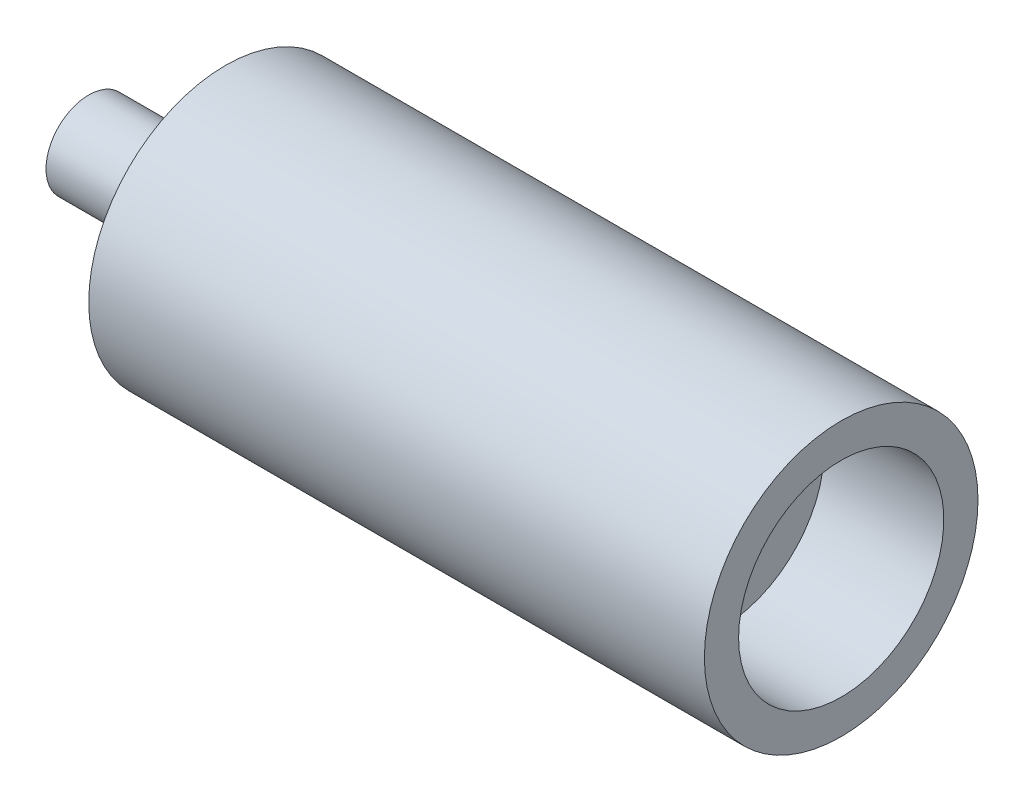
from build123d import *


with BuildPart() as part:
    # Sketch2 → Revolve1 (revolve)
    with BuildSketch(Plane.XY):
        Polygon((0, 0), (0, 12.5), (30, 12.5), (30, 20), (33, 25), (35, 25), (35, 32.5), (40, 32.5), (40, 40), (220, 40), (220, 30), (185, 30), (185, 0), align=None)
    revolve(axis=Axis((37.760080772, 0, 0), (1, 0, 0)))


solid = part.part
